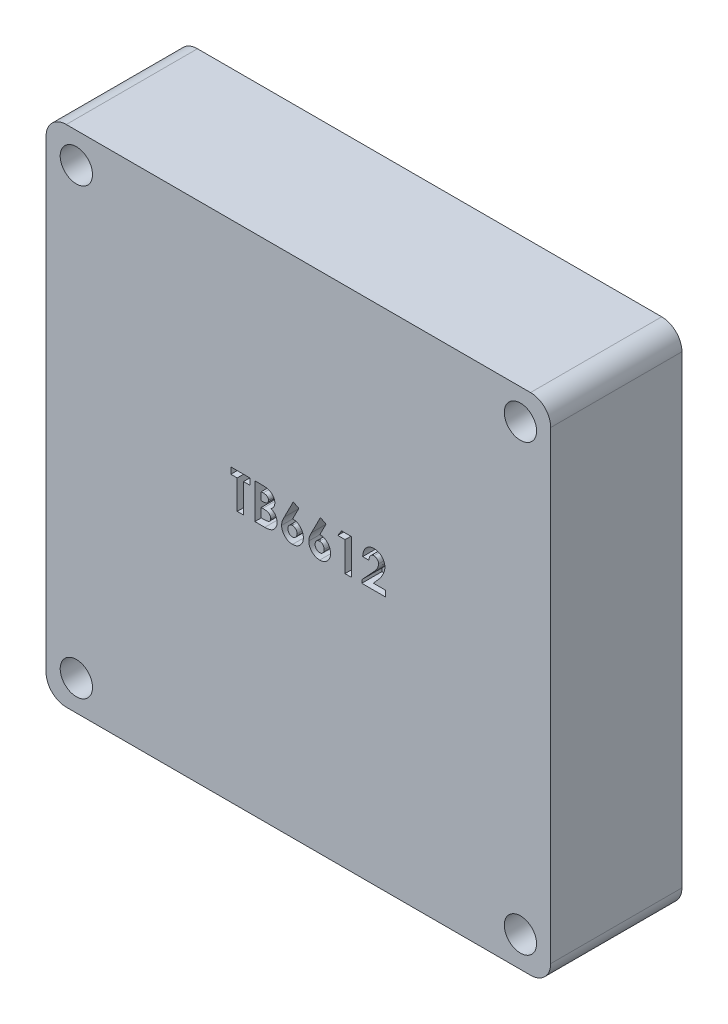
from build123d import *

# Parameters (mm, degrees)
SKETCH_1_W          = 50
SKETCH_1_H          = 50
SKETCH_1_R          = 1.6
EXTRUDE_1_DEPTH     = 13
FILLET_1_R          = 2
CUT_EXTRUDE_1_DEPTH = 2


with BuildPart() as part:
    # 草图1 → 凸台-拉伸1 (new body)
    with BuildSketch(Plane.XY):
        with Locations((-25, 25)):
            Rectangle(SKETCH_1_W, SKETCH_1_H)
        with Locations((-47, 47)):
            Circle(SKETCH_1_R, mode=Mode.SUBTRACT)
        with Locations((-47, 3)):
            Circle(SKETCH_1_R, mode=Mode.SUBTRACT)
        with Locations((-3, 3)):
            Circle(SKETCH_1_R, mode=Mode.SUBTRACT)
        with Locations((-3, 47)):
            Circle(SKETCH_1_R, mode=Mode.SUBTRACT)
    extrude(amount=EXTRUDE_1_DEPTH)

    # 圆角1
    fillet_1_edges = [part.edges().sort_by_distance(p)[0] for p in [
        (0, 0, 6.5),
        (-50, 0, 6.5),
        (-50, 50, 6.5),
        (0, 50, 6.5),
    ]]
    fillet(fillet_1_edges, radius=FILLET_1_R)

    # 草图2 → 切除-拉伸1 (cut)
    with BuildSketch(Plane.XY.offset(13)):
        Polygon((-31.689258188, 28.772255368), (-29.804642803, 28.772255368), (-29.804642803, 28.14405024), (-30.432847932, 28.14405024), (-30.432847932, 25.272255368), (-31.06105306, 25.272255368), (-31.06105306, 28.14405024), (-31.689258188, 28.14405024), align=None)
        with BuildLine():
            Line((-29.31105306, 25.272255368), (-29.31105306, 28.772255368))
            Line((-29.31105306, 28.772255368), (-28.750155624, 28.772255368))
            add(Edge.make_bspline(
                [(-28.750155624, 28.772255368), (-28.710889296, 28.772259849), (-28.634909697, 28.77226852), (-28.525290963, 28.76841907), (-28.423628846, 28.763439376), (-28.330246872, 28.757868255), (-28.2449861, 28.748268101), (-28.167976182, 28.738150588), (-28.099063252, 28.72594949), (-28.056458133, 28.715004728), (-28.036413637, 28.709855528)],
                knots=[0, 0, 0, 0, 0.000117791, 0.000227922, 0.000329003, 0.000423165, 0.000508489, 0.000586326, 0.000656186, 0.000718254, 0.000718254, 0.000718254, 0.000718254], degree=3))
            add(Edge.make_bspline(
                [(-28.036413637, 28.709855528), (-28.010093178, 28.702592491), (-27.958443989, 28.68834008), (-27.884465868, 28.659556721), (-27.814287301, 28.627561976), (-27.747993974, 28.591061956), (-27.685992954, 28.549616004), (-27.628519866, 28.502895192), (-27.574335159, 28.452774891), (-27.525362807, 28.397858262), (-27.48109987, 28.339828672), (-27.442643313, 28.278701324), (-27.409229494, 28.215410897), (-27.382489687, 28.149160922), (-27.362341745, 28.080256498), (-27.347605624, 28.008991858), (-27.338054622, 27.935141503), (-27.337152178, 27.884898693), (-27.336694085, 27.859394791)],
                knots=[0, 0, 0, 0, 8.1863e-05, 0.000160642, 0.000237816, 0.000313134, 0.000387417, 0.000461218, 0.000535129, 0.000608609, 0.000681668, 0.000753832, 0.000825019, 0.000896106, 0.000967761, 0.001040089, 0.001114269, 0.001190743, 0.001190743, 0.001190743, 0.001190743], degree=3))
            add(Edge.make_bspline(
                [(-27.336694085, 27.859394791), (-27.337891861, 27.826628972), (-27.340249535, 27.762133483), (-27.35531052, 27.667401279), (-27.383552212, 27.57786573), (-27.420505779, 27.491876729), (-27.470751076, 27.409755016), (-27.534552887, 27.331539639), (-27.610877831, 27.254822227), (-27.669423275, 27.208835314), (-27.699875175, 27.184915624)],
                knots=[0, 0, 0, 0, 9.8317e-05, 0.000193525, 0.000286672, 0.000379289, 0.00047368, 0.000574417, 0.000681503, 0.000797579, 0.000797579, 0.000797579, 0.000797579], degree=3))
            add(Edge.make_bspline(
                [(-27.699875175, 27.184915624), (-27.675198417, 27.172318353), (-27.62681412, 27.14761859), (-27.558122634, 27.107019551), (-27.494521816, 27.063837325), (-27.435726499, 27.018940755), (-27.382969983, 26.970426609), (-27.334073862, 26.921090341), (-27.291450418, 26.868105186), (-27.253335249, 26.813359637), (-27.220206164, 26.756060972), (-27.191354384, 26.696305955), (-27.16698432, 26.633890449), (-27.14634712, 26.569132101), (-27.13095589, 26.50180817), (-27.120920482, 26.43189458), (-27.113236745, 26.359629771), (-27.112639023, 26.310404787), (-27.112335111, 26.285376362)],
                knots=[0, 0, 0, 0, 8.3106e-05, 0.000162948, 0.000239177, 0.000313644, 0.000384624, 0.000454039, 0.000521819, 0.000588334, 0.000653992, 0.000720158, 0.00078721, 0.000854842, 0.000923894, 0.000994098, 0.001066653, 0.001141702, 0.001141702, 0.001141702, 0.001141702], degree=3))
            add(Edge.make_bspline(
                [(-27.112335111, 26.285376362), (-27.114307295, 26.237573499), (-27.118199393, 26.143234743), (-27.146656514, 26.004723781), (-27.195992119, 25.873402827), (-27.262239664, 25.749793805), (-27.343869385, 25.637474995), (-27.437720155, 25.539084692), (-27.542847113, 25.455799484), (-27.639839438, 25.399588431), (-27.723730161, 25.361865557), (-27.793215279, 25.338542898), (-27.867840823, 25.316936821), (-27.948973754, 25.301764589), (-28.035143242, 25.287877293), (-28.127189445, 25.279302988), (-28.224940331, 25.273492394), (-28.292079865, 25.272676046), (-28.32667806, 25.272255368)],
                knots=[0, 0, 0, 0, 0.000143365, 0.000282931, 0.000422024, 0.000562867, 0.000702406, 0.000837288, 0.000969562, 0.001103403, 0.001172455, 0.001245183, 0.001323096, 0.001405322, 0.001492583, 0.001584881, 0.001682498, 0.001786285, 0.001786285, 0.001786285, 0.001786285], degree=3))
            Line((-28.32667806, 25.272255368), (-29.31105306, 25.272255368))
        make_face()
        with BuildLine():
            Line((-28.682847932, 28.14405024), (-28.682847932, 27.381229727))
            Line((-28.682847932, 27.381229727), (-28.515980944, 27.381229727))
            add(Edge.make_bspline(
                [(-28.515980944, 27.381229727), (-28.493302222, 27.381427494), (-28.44952232, 27.381809271), (-28.386286895, 27.386726431), (-28.327488163, 27.39511541), (-28.273349133, 27.406820146), (-28.223365481, 27.421683454), (-28.177856518, 27.439567214), (-28.137022337, 27.461387346), (-28.089582463, 27.493889395), (-28.039435095, 27.541717616), (-27.995290931, 27.610815391), (-27.969290313, 27.690277568), (-27.966394546, 27.746320449), (-27.964899214, 27.775260176)],
                knots=[0, 0, 0, 0, 6.8023e-05, 0.000131315, 0.000190113, 0.000246084, 0.000297324, 0.000346407, 0.000392516, 0.000435884, 0.000518691, 0.000598437, 0.000679585, 0.000766233, 0.000766233, 0.000766233, 0.000766233], degree=3))
            add(Edge.make_bspline(
                [(-27.964899214, 27.775260176), (-27.966095753, 27.802367038), (-27.968409214, 27.854777068), (-27.994588493, 27.928365417), (-28.035250089, 27.993579755), (-28.083256818, 28.038213637), (-28.128464483, 28.068697262), (-28.167174059, 28.088769431), (-28.209660725, 28.106737831), (-28.256746979, 28.120476908), (-28.30816393, 28.130786228), (-28.36366182, 28.138357188), (-28.4233364, 28.143510306), (-28.464553759, 28.143866401), (-28.485832707, 28.14405024)],
                knots=[0, 0, 0, 0, 8.0997e-05, 0.000156604, 0.000231296, 0.000309653, 0.000351072, 0.000394666, 0.000440239, 0.000489262, 0.000541514, 0.000597437, 0.000657234, 0.000721051, 0.000721051, 0.000721051, 0.000721051], degree=3))
            Line((-28.485832707, 28.14405024), (-28.682847932, 28.14405024))
        make_face(mode=Mode.SUBTRACT)
        with BuildLine():
            Line((-28.682847932, 26.797896394), (-28.682847932, 25.900460496))
            Line((-28.682847932, 25.900460496), (-28.501958508, 25.900460496))
            add(Edge.make_bspline(
                [(-28.501958508, 25.900460496), (-28.466196439, 25.900664804), (-28.397439398, 25.90105761), (-28.29894506, 25.905803646), (-28.209389082, 25.914357539), (-28.129008755, 25.925036385), (-28.057680961, 25.939504552), (-27.995646805, 25.957898971), (-27.94205557, 25.978136037), (-27.89722859, 26.003131215), (-27.860607516, 26.032219405), (-27.827560836, 26.061948233), (-27.800616632, 26.096243245), (-27.779297875, 26.133632251), (-27.760846528, 26.173186482), (-27.749717979, 26.216450515), (-27.741245093, 26.262142108), (-27.740778807, 26.293745995), (-27.740540239, 26.309915624)],
                knots=[0, 0, 0, 0, 0.000107281, 0.000206261, 0.0002957, 0.000377105, 0.000449433, 0.000513769, 0.000571055, 0.000620973, 0.00066697, 0.000711118, 0.000754041, 0.00079709, 0.000840088, 0.000884486, 0.000930707, 0.00097913, 0.00097913, 0.00097913, 0.00097913], degree=3))
            add(Edge.make_bspline(
                [(-27.740540239, 26.309915624), (-27.741066349, 26.32840585), (-27.742091071, 26.364419836), (-27.750459981, 26.417058119), (-27.765669024, 26.466199449), (-27.784825556, 26.513100436), (-27.811482888, 26.556081861), (-27.843164217, 26.596631148), (-27.881443349, 26.633375173), (-27.924490467, 26.668536353), (-27.974700668, 26.69932187), (-28.032097509, 26.72603376), (-28.096992801, 26.748342547), (-28.169587565, 26.766104817), (-28.24956355, 26.781179411), (-28.337504493, 26.790180607), (-28.432677992, 26.796875192), (-28.498672845, 26.797548258), (-28.532807867, 26.797896394)],
                knots=[0, 0, 0, 0, 5.546e-05, 0.00010802, 0.00015926, 0.000209526, 0.000259547, 0.000310464, 0.000363513, 0.000418371, 0.000476935, 0.000539665, 0.000607959, 0.000682439, 0.000763712, 0.0008519, 0.000947461, 0.001049847, 0.001049847, 0.001049847, 0.001049847], degree=3))
            Line((-28.532807867, 26.797896394), (-28.682847932, 26.797896394))
        make_face(mode=Mode.SUBTRACT)
        with BuildLine():
            Line((-25.510972932, 28.861998958), (-24.954983348, 28.580147996))
            Line((-24.954983348, 28.580147996), (-25.56495931, 27.381229727))
            add(Edge.make_bspline(
                [(-25.56495931, 27.381229727), (-25.528922502, 27.380296716), (-25.4579421, 27.378458998), (-25.353508841, 27.36360625), (-25.253668702, 27.337929411), (-25.157414998, 27.303894831), (-25.06592434, 27.258186051), (-24.97772322, 27.203813073), (-24.895093445, 27.137499378), (-24.816140386, 27.064027322), (-24.744348775, 26.982630843), (-24.681985069, 26.895167741), (-24.6276362, 26.803766004), (-24.585387577, 26.706380752), (-24.55130843, 26.604626258), (-24.526718826, 26.498095764), (-24.512689769, 26.386480783), (-24.510755629, 26.31065567), (-24.509771008, 26.272055048)],
                knots=[0, 0, 0, 0, 0.000108084, 0.00021289, 0.000315599, 0.000416951, 0.000518544, 0.000621847, 0.000727186, 0.000835814, 0.000945104, 0.001052119, 0.001157697, 0.001263483, 0.001369906, 0.001479265, 0.001590926, 0.001706716, 0.001706716, 0.001706716, 0.001706716], degree=3))
            add(Edge.make_bspline(
                [(-24.509771008, 26.272055048), (-24.51069368, 26.234846389), (-24.512517405, 26.161300827), (-24.52759291, 26.053281101), (-24.551955718, 25.94964249), (-24.586775062, 25.850591975), (-24.631033265, 25.755645393), (-24.685158049, 25.66485846), (-24.749598275, 25.578909597), (-24.822688985, 25.498255495), (-24.902589739, 25.424738685), (-24.986809487, 25.359392666), (-25.076061894, 25.305414374), (-25.168659987, 25.259828442), (-25.266308553, 25.225811461), (-25.367546276, 25.200134533), (-25.473140872, 25.185317831), (-25.544815777, 25.183454614), (-25.581085111, 25.182511778)],
                knots=[0, 0, 0, 0, 0.000111586, 0.000220558, 0.000326504, 0.0004305, 0.000534951, 0.000640282, 0.000746993, 0.000856694, 0.000966349, 0.001072365, 0.001175896, 0.001278749, 0.001381422, 0.00148549, 0.001591684, 0.001700469, 0.001700469, 0.001700469, 0.001700469], degree=3))
            add(Edge.make_bspline(
                [(-25.581085111, 25.182511778), (-25.619011812, 25.183285513), (-25.693589538, 25.184806959), (-25.802715416, 25.201843135), (-25.907376524, 25.227488724), (-26.006984651, 25.264106268), (-26.10215923, 25.310731764), (-26.191779752, 25.368426126), (-26.276601146, 25.436553139), (-26.35571909, 25.513580054), (-26.426998463, 25.597952499), (-26.490573705, 25.685553065), (-26.544358443, 25.776519216), (-26.587895934, 25.87075369), (-26.621864894, 25.967956207), (-26.645500362, 26.068311248), (-26.660901051, 26.171552622), (-26.66270643, 26.241618061), (-26.663617162, 26.2769629)],
                knots=[0, 0, 0, 0, 0.000113688, 0.000223552, 0.000330511, 0.000436536, 0.000541264, 0.000647844, 0.000755588, 0.000867146, 0.000978556, 0.001086549, 0.001191524, 0.001295043, 0.001397484, 0.001499857, 0.001603968, 0.001709951, 0.001709951, 0.001709951, 0.001709951], degree=3))
            add(Edge.make_bspline(
                [(-26.663617162, 26.2769629), (-26.663135949, 26.304333344), (-26.662170845, 26.359226586), (-26.652472121, 26.441426233), (-26.637726654, 26.523841646), (-26.620634727, 26.593386382), (-26.603035187, 26.652193734), (-26.585321115, 26.701960807), (-26.563368426, 26.757191375), (-26.538273251, 26.818026477), (-26.509246437, 26.884392926), (-26.476439616, 26.956109826), (-26.439771113, 27.03372027), (-26.41362142, 27.087026628), (-26.399995367, 27.114803445)],
                knots=[0, 0, 0, 0, 8.2079e-05, 0.000164615, 0.000247957, 0.000333152, 0.000379287, 0.000432063, 0.000491563, 0.000557577, 0.000629478, 0.000708857, 0.000794164, 0.00088698, 0.00088698, 0.00088698, 0.00088698], degree=3))
            Line((-26.399995367, 27.114803445), (-25.510972932, 28.861998958))
        make_face()
        with BuildLine():
            add(Edge.make_bspline(
                [(-25.595107547, 26.797896394), (-25.625250741, 26.796513789), (-25.684237015, 26.793808213), (-25.768106675, 26.765474107), (-25.844576776, 26.721024946), (-25.910862006, 26.659120893), (-25.966303501, 26.585143119), (-26.007043857, 26.500761586), (-26.031551445, 26.407102343), (-26.034097627, 26.341617362), (-26.035412034, 26.307812259)],
                knots=[0, 0, 0, 0, 9.0137e-05, 0.000176386, 0.000262485, 0.000353792, 0.000446481, 0.00053836, 0.00063325, 0.000734506, 0.000734506, 0.000734506, 0.000734506], degree=3))
            add(Edge.make_bspline(
                [(-26.035412034, 26.307812259), (-26.033855735, 26.273995899), (-26.030828629, 26.208220819), (-26.005399523, 26.113669773), (-25.963764187, 26.027372033), (-25.905373282, 25.952413893), (-25.8368232, 25.890192833), (-25.760809289, 25.844177384), (-25.67859949, 25.815908584), (-25.621732963, 25.812459415), (-25.593004182, 25.810716907)],
                knots=[0, 0, 0, 0, 0.000101311, 0.000197058, 0.000291441, 0.000386941, 0.000480277, 0.000567692, 0.000651944, 0.000737965, 0.000737965, 0.000737965, 0.000737965], degree=3))
            add(Edge.make_bspline(
                [(-25.593004182, 25.810716907), (-25.562663341, 25.812490451), (-25.503159682, 25.815968678), (-25.417321752, 25.843047979), (-25.338908289, 25.888292518), (-25.269575619, 25.950314372), (-25.210020173, 26.024417139), (-25.16881382, 26.11122178), (-25.142209115, 26.206455262), (-25.139418765, 26.273269092), (-25.137976137, 26.307812259)],
                knots=[0, 0, 0, 0, 9.0903e-05, 0.000178276, 0.000267153, 0.000360547, 0.000455923, 0.000550306, 0.000646911, 0.000750319, 0.000750319, 0.000750319, 0.000750319], degree=3))
            add(Edge.make_bspline(
                [(-25.137976137, 26.307812259), (-25.139619554, 26.341597623), (-25.142802224, 26.407026926), (-25.166707844, 26.501124941), (-25.209389716, 26.585181236), (-25.26608562, 26.659426262), (-25.334652035, 26.721302711), (-25.414182626, 26.765824647), (-25.501883592, 26.793758014), (-25.563579825, 26.796496821), (-25.595107547, 26.797896394)],
                knots=[0, 0, 0, 0, 0.000101311, 0.000196202, 0.000288699, 0.000382233, 0.000475101, 0.000563632, 0.000653892, 0.000748218, 0.000748218, 0.000748218, 0.000748218], degree=3))
        make_face(mode=Mode.SUBTRACT)
        with BuildLine():
            Line((-22.818665239, 28.861998958), (-22.262675656, 28.580147996))
            Line((-22.262675656, 28.580147996), (-22.872651617, 27.381229727))
            add(Edge.make_bspline(
                [(-22.872651617, 27.381229727), (-22.83661481, 27.380296716), (-22.765634408, 27.378458998), (-22.661201149, 27.36360625), (-22.561361009, 27.337929411), (-22.465107305, 27.303894831), (-22.373616647, 27.258186051), (-22.285415527, 27.203813073), (-22.202785753, 27.137499378), (-22.123832694, 27.064027322), (-22.052041083, 26.982630843), (-21.989677377, 26.895167741), (-21.935328508, 26.803766004), (-21.893079884, 26.706380752), (-21.859000738, 26.604626258), (-21.834411134, 26.498095764), (-21.820382077, 26.386480783), (-21.818447937, 26.31065567), (-21.817463316, 26.272055048)],
                knots=[0, 0, 0, 0, 0.000108084, 0.00021289, 0.000315599, 0.000416951, 0.000518544, 0.000621847, 0.000727186, 0.000835814, 0.000945104, 0.001052119, 0.001157697, 0.001263483, 0.001369906, 0.001479265, 0.001590926, 0.001706716, 0.001706716, 0.001706716, 0.001706716], degree=3))
            add(Edge.make_bspline(
                [(-21.817463316, 26.272055048), (-21.818385987, 26.234846389), (-21.820209713, 26.161300827), (-21.835285218, 26.053281101), (-21.859648025, 25.94964249), (-21.89446737, 25.850591975), (-21.938725573, 25.755645393), (-21.992850357, 25.66485846), (-22.057290582, 25.578909597), (-22.130381292, 25.498255495), (-22.210282047, 25.424738685), (-22.294501794, 25.359392666), (-22.383754202, 25.305414374), (-22.476352295, 25.259828442), (-22.574000861, 25.225811461), (-22.675238584, 25.200134533), (-22.780833179, 25.185317831), (-22.852508085, 25.183454614), (-22.888777419, 25.182511778)],
                knots=[0, 0, 0, 0, 0.000111586, 0.000220558, 0.000326504, 0.0004305, 0.000534951, 0.000640282, 0.000746993, 0.000856694, 0.000966349, 0.001072365, 0.001175896, 0.001278749, 0.001381422, 0.00148549, 0.001591684, 0.001700469, 0.001700469, 0.001700469, 0.001700469], degree=3))
            add(Edge.make_bspline(
                [(-22.888777419, 25.182511778), (-22.92670412, 25.183285513), (-23.001281846, 25.184806959), (-23.110407723, 25.201843135), (-23.215068832, 25.227488724), (-23.314676959, 25.264106268), (-23.409851538, 25.310731764), (-23.49947206, 25.368426126), (-23.584293453, 25.436553139), (-23.663411398, 25.513580054), (-23.73469077, 25.597952499), (-23.798266013, 25.685553065), (-23.85205075, 25.776519216), (-23.895588241, 25.87075369), (-23.929557202, 25.967956207), (-23.95319267, 26.068311248), (-23.968593358, 26.171552622), (-23.970398738, 26.241618061), (-23.97130947, 26.2769629)],
                knots=[0, 0, 0, 0, 0.000113688, 0.000223552, 0.000330511, 0.000436536, 0.000541264, 0.000647844, 0.000755588, 0.000867146, 0.000978556, 0.001086549, 0.001191524, 0.001295043, 0.001397484, 0.001499857, 0.001603968, 0.001709951, 0.001709951, 0.001709951, 0.001709951], degree=3))
            add(Edge.make_bspline(
                [(-23.97130947, 26.2769629), (-23.970828257, 26.304333344), (-23.969863152, 26.359226586), (-23.960164428, 26.441426233), (-23.945418961, 26.523841646), (-23.928327034, 26.593386382), (-23.910727495, 26.652193734), (-23.893013423, 26.701960807), (-23.871060734, 26.757191375), (-23.845965558, 26.818026477), (-23.816938744, 26.884392926), (-23.784131923, 26.956109826), (-23.747463421, 27.03372027), (-23.721313728, 27.087026628), (-23.707687675, 27.114803445)],
                knots=[0, 0, 0, 0, 8.2079e-05, 0.000164615, 0.000247957, 0.000333152, 0.000379287, 0.000432063, 0.000491563, 0.000557577, 0.000629478, 0.000708857, 0.000794164, 0.00088698, 0.00088698, 0.00088698, 0.00088698], degree=3))
            Line((-23.707687675, 27.114803445), (-22.818665239, 28.861998958))
        make_face()
        with BuildLine():
            add(Edge.make_bspline(
                [(-22.902799855, 26.797896394), (-22.932943049, 26.796513789), (-22.991929323, 26.793808213), (-23.075798983, 26.765474107), (-23.152269084, 26.721024946), (-23.218554313, 26.659120893), (-23.273995809, 26.585143119), (-23.314736165, 26.500761586), (-23.339243753, 26.407102343), (-23.341789935, 26.341617362), (-23.343104342, 26.307812259)],
                knots=[0, 0, 0, 0, 9.0137e-05, 0.000176386, 0.000262485, 0.000353792, 0.000446481, 0.00053836, 0.00063325, 0.000734506, 0.000734506, 0.000734506, 0.000734506], degree=3))
            add(Edge.make_bspline(
                [(-23.343104342, 26.307812259), (-23.341548043, 26.273995899), (-23.338520937, 26.208220819), (-23.313091831, 26.113669773), (-23.271456494, 26.027372033), (-23.21306559, 25.952413893), (-23.144515508, 25.890192833), (-23.068501597, 25.844177384), (-22.986291797, 25.815908584), (-22.929425271, 25.812459415), (-22.900696489, 25.810716907)],
                knots=[0, 0, 0, 0, 0.000101311, 0.000197058, 0.000291441, 0.000386941, 0.000480277, 0.000567692, 0.000651944, 0.000737965, 0.000737965, 0.000737965, 0.000737965], degree=3))
            add(Edge.make_bspline(
                [(-22.900696489, 25.810716907), (-22.870355648, 25.812490451), (-22.81085199, 25.815968678), (-22.72501406, 25.843047979), (-22.646600596, 25.888292518), (-22.577267926, 25.950314372), (-22.517712481, 26.024417139), (-22.476506128, 26.11122178), (-22.449901423, 26.206455262), (-22.447111073, 26.273269092), (-22.445668444, 26.307812259)],
                knots=[0, 0, 0, 0, 9.0903e-05, 0.000178276, 0.000267153, 0.000360547, 0.000455923, 0.000550306, 0.000646911, 0.000750319, 0.000750319, 0.000750319, 0.000750319], degree=3))
            add(Edge.make_bspline(
                [(-22.445668444, 26.307812259), (-22.447311862, 26.341597623), (-22.450494531, 26.407026926), (-22.474400152, 26.501124941), (-22.517082023, 26.585181236), (-22.573777927, 26.659426262), (-22.642344343, 26.721302711), (-22.721874933, 26.765824647), (-22.809575899, 26.793758014), (-22.871272132, 26.796496821), (-22.902799855, 26.797896394)],
                knots=[0, 0, 0, 0, 0.000101311, 0.000196202, 0.000288699, 0.000382233, 0.000475101, 0.000563632, 0.000653892, 0.000748218, 0.000748218, 0.000748218, 0.000748218], degree=3))
        make_face(mode=Mode.SUBTRACT)
        Polygon((-20.724414438, 28.772255368), (-19.753360752, 28.772255368), (-19.753360752, 25.272255368), (-20.38156588, 25.272255368), (-20.38156588, 28.188922035), (-21.099514598, 28.188922035), align=None)
        with BuildLine():
            Line((-18.003360752, 27.605588701), (-18.63156588, 27.605588701))
            add(Edge.make_bspline(
                [(-18.63156588, 27.605588701), (-18.628852759, 27.653109096), (-18.623551482, 27.745961094), (-18.602464343, 27.880831593), (-18.574208301, 28.008269385), (-18.536496861, 28.127828676), (-18.489109969, 28.239466024), (-18.433267013, 28.343562006), (-18.367541331, 28.439568554), (-18.293331782, 28.527022672), (-18.21189824, 28.605478567), (-18.124931345, 28.675042493), (-18.031100822, 28.732444893), (-17.932121031, 28.779681755), (-17.828008825, 28.817421812), (-17.717779141, 28.842654095), (-17.602386406, 28.859741643), (-17.523390735, 28.861236872), (-17.48312838, 28.861998958)],
                knots=[0, 0, 0, 0, 0.000142716, 0.000278858, 0.000408976, 0.000534035, 0.000654361, 0.000772316, 0.000887831, 0.001002741, 0.001115793, 0.001226606, 0.001336154, 0.001444972, 0.001555191, 0.0016676, 0.00178371, 0.001904402, 0.001904402, 0.001904402, 0.001904402], degree=3))
            add(Edge.make_bspline(
                [(-17.48312838, 28.861998958), (-17.433706911, 28.860456878), (-17.33722462, 28.857446376), (-17.1970282, 28.831765796), (-17.066100071, 28.788811059), (-16.944535408, 28.728791962), (-16.83336911, 28.652543991), (-16.732619614, 28.561630764), (-16.645333743, 28.454144875), (-16.57095808, 28.334558636), (-16.509160793, 28.207933638), (-16.465855829, 28.07699814), (-16.437391942, 27.945226638), (-16.434356092, 27.856498379), (-16.432847932, 27.812419631)],
                knots=[0, 0, 0, 0, 0.000148176, 0.000289274, 0.00042585, 0.000560365, 0.000694549, 0.000829057, 0.000966049, 0.001108444, 0.001250813, 0.001387611, 0.0015214, 0.001653479, 0.001653479, 0.001653479, 0.001653479], degree=3))
            add(Edge.make_bspline(
                [(-16.432847932, 27.812419631), (-16.43343513, 27.785757689), (-16.434617014, 27.732093786), (-16.442834815, 27.650887129), (-16.45516314, 27.568168655), (-16.47375125, 27.484009287), (-16.496932146, 27.398385433), (-16.525053924, 27.311040852), (-16.558768896, 27.222470754), (-16.597514428, 27.131678299), (-16.643737945, 27.038368719), (-16.697558805, 26.941143267), (-16.760405537, 26.840088189), (-16.831519031, 26.734632897), (-16.911244667, 26.624943708), (-16.999971641, 26.511351041), (-17.096678026, 26.393454633), (-17.165313267, 26.3146475), (-17.200576297, 26.274158413)],
                knots=[0, 0, 0, 0, 7.9977e-05, 0.000160974, 0.000244663, 0.00033075, 0.000419361, 0.000510712, 0.000605902, 0.000703579, 0.00080674, 0.00091815, 0.001036838, 0.001163625, 0.001299659, 0.001443551, 0.001595983, 0.001757052, 0.001757052, 0.001757052, 0.001757052], degree=3))
            Line((-17.200576297, 26.274158413), (-17.565860752, 25.855588701))
            Line((-17.565860752, 25.855588701), (-16.387976137, 25.855588701))
            Line((-16.387976137, 25.855588701), (-16.387976137, 25.272255368))
            Line((-16.387976137, 25.272255368), (-18.72130947, 25.272255368))
            Line((-18.72130947, 25.272255368), (-18.72130947, 25.590564663))
            Line((-18.72130947, 25.590564663), (-17.685051457, 26.693429246))
            add(Edge.make_bspline(
                [(-17.685051457, 26.693429246), (-17.655049125, 26.725600149), (-17.596943504, 26.787905646), (-17.514265194, 26.879407898), (-17.439448627, 26.96624135), (-17.374045185, 27.049330605), (-17.31462258, 27.125980584), (-17.263830461, 27.198501615), (-17.22120412, 27.26623808), (-17.174927181, 27.347916427), (-17.130979301, 27.44533239), (-17.090654461, 27.557559574), (-17.066073681, 27.664822915), (-17.062680756, 27.734718014), (-17.06105306, 27.768248958)],
                knots=[0, 0, 0, 0, 0.000131967, 0.000255582, 0.000369957, 0.000475731, 0.00057277, 0.00066088, 0.000741219, 0.000812792, 0.000942363, 0.001061215, 0.001170268, 0.001270825, 0.001270825, 0.001270825, 0.001270825], degree=3))
            add(Edge.make_bspline(
                [(-17.06105306, 27.768248958), (-17.062270049, 27.800687559), (-17.06462816, 27.86354255), (-17.090541893, 27.952953441), (-17.130688348, 28.033905874), (-17.187260372, 28.103980902), (-17.255786811, 28.161566199), (-17.334975549, 28.204396525), (-17.424180964, 28.229109426), (-17.486715659, 28.232202599), (-17.518885592, 28.23379383)],
                knots=[0, 0, 0, 0, 9.7062e-05, 0.000188073, 0.000276808, 0.000366596, 0.000456186, 0.000543702, 0.000634713, 0.000731135, 0.000731135, 0.000731135, 0.000731135], degree=3))
            add(Edge.make_bspline(
                [(-17.518885592, 28.23379383), (-17.535504989, 28.23320601), (-17.568222941, 28.232048792), (-17.616315773, 28.224345507), (-17.662079557, 28.210769271), (-17.706023671, 28.192579026), (-17.747679132, 28.168467726), (-17.78694087, 28.138746707), (-17.824222557, 28.104171247), (-17.859353206, 28.064849461), (-17.891326683, 28.020966335), (-17.919725408, 27.972922653), (-17.943206426, 27.920748238), (-17.963879968, 27.86513187), (-17.979824392, 27.805476185), (-17.991433911, 27.742138216), (-18.000259853, 27.675221004), (-18.002308315, 27.629221714), (-18.003360752, 27.605588701)],
                knots=[0, 0, 0, 0, 4.9859e-05, 9.8155e-05, 0.000145635, 0.000192772, 0.000240515, 0.000289593, 0.000340201, 0.000392836, 0.000447528, 0.000502841, 0.000559939, 0.000618941, 0.00068068, 0.000744897, 0.000812032, 0.000882971, 0.000882971, 0.000882971, 0.000882971], degree=3))
        make_face()
    extrude(amount=-CUT_EXTRUDE_1_DEPTH, mode=Mode.SUBTRACT)


solid = part.part
